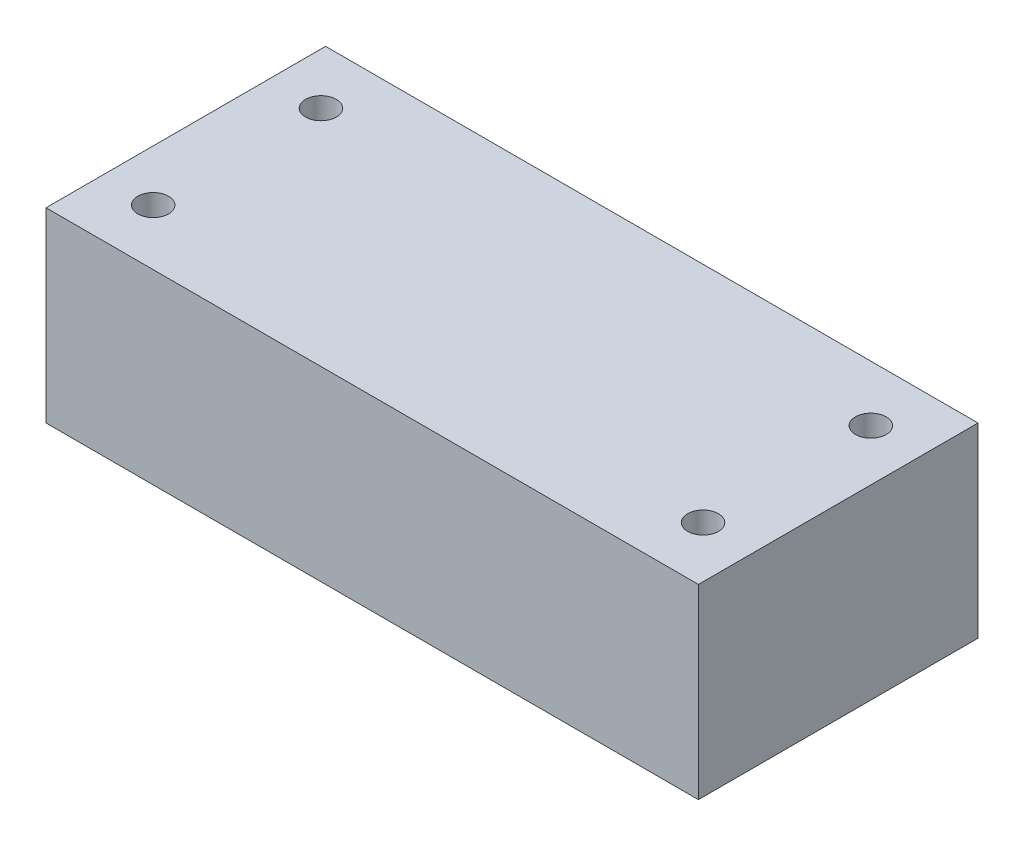
from build123d import *

# Parameters (mm, degrees)
SKETCH2_W           = 70
SKETCH2_H           = 30
BOSS_EXTRUDE1_DEPTH = 20
SKETCH3_R           = 1.65
CUT_EXTRUDE1_DEPTH  = 30


with BuildPart() as part:
    # Sketch2 → Boss-Extrude1 (new body)
    with BuildSketch(Plane(origin=(0, 0, 0), x_dir=(1, 0, 0), z_dir=(0, 1, 0))):
        Rectangle(SKETCH2_W, SKETCH2_H)
    extrude(amount=BOSS_EXTRUDE1_DEPTH)

    # Sketch3 → Cut-Extrude1 (cut)
    with BuildSketch(Plane(origin=(0, 20, 0), x_dir=(1, 0, 0), z_dir=(0, 1, 0))):
        with Locations((-29.5, 9)):
            Circle(SKETCH3_R)
        with Locations((29.5, 9)):
            Circle(SKETCH3_R)
        with Locations((29.5, -9)):
            Circle(SKETCH3_R)
        with Locations((-29.5, -9)):
            Circle(SKETCH3_R)
    extrude(amount=-CUT_EXTRUDE1_DEPTH, mode=Mode.SUBTRACT)


solid = part.part
